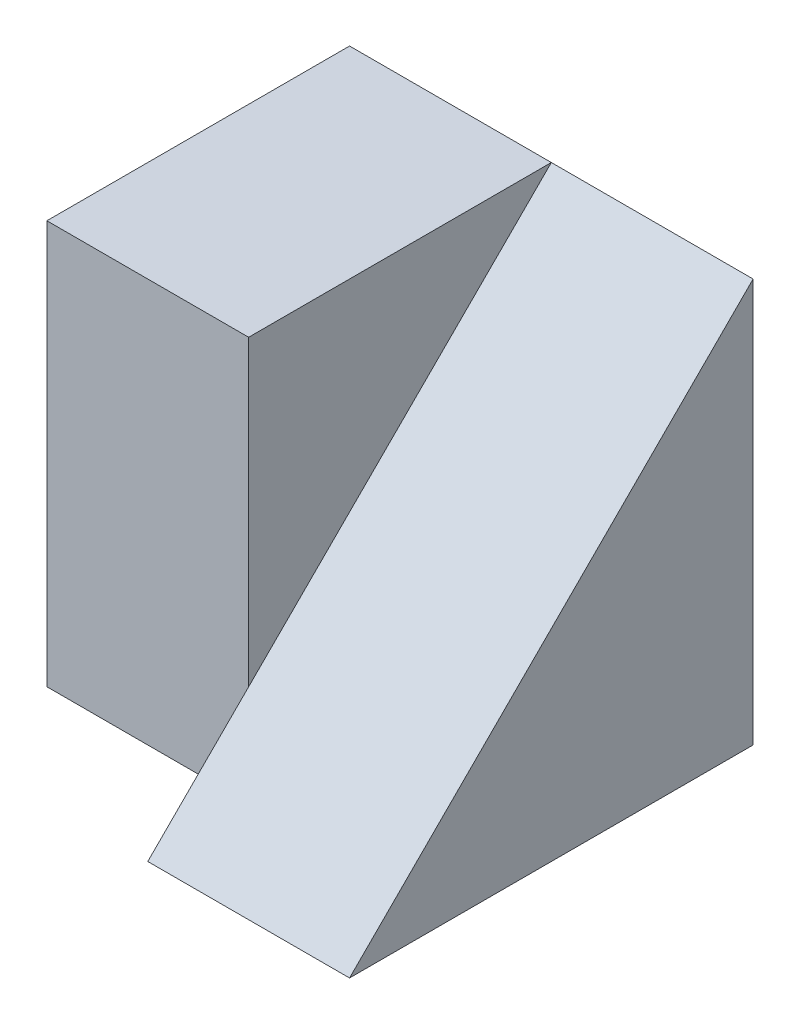
from build123d import *

# Parameters (mm, degrees)
SKETCH1_W           = 4
SKETCH1_H           = 4
BOSS_EXTRUDE1_DEPTH = 2
SKETCH2_W           = 3
SKETCH2_H           = 4
BOSS_EXTRUDE2_DEPTH = 2
CUT_EXTRUDE1_DEPTH  = 2
CUT_EXTRUDE2_DEPTH  = 2


with BuildPart() as part:
    # Sketch1 → Boss-Extrude1 (new body)
    with BuildSketch(Plane(origin=(0, 0, 0), x_dir=(0, 0, -1), z_dir=(1, 0, 0))):
        with Locations((2, 2)):
            Rectangle(SKETCH1_W, SKETCH1_H)
    extrude(amount=BOSS_EXTRUDE1_DEPTH)

    # Sketch2 → Boss-Extrude2 (add)
    with BuildSketch(Plane.ZY):
        with Locations((-2.5, 2)):
            Rectangle(SKETCH2_W, SKETCH2_H)
    extrude(amount=BOSS_EXTRUDE2_DEPTH)

    # Sketch3 → Cut-Extrude1 (cut)
    with BuildSketch(Plane(origin=(2, 0, 0), x_dir=(0, 0, -1), z_dir=(1, 0, 0))):
        Polygon((4, 4), (0, 0), (0, 4), align=None)
    extrude(amount=-CUT_EXTRUDE1_DEPTH, mode=Mode.SUBTRACT)

    # Sketch4 → Cut-Extrude2 (cut)
    with BuildSketch(Plane.ZY.offset(2)):
        Polygon((-1, 0), (-4, 4), (-4, 0), align=None)
    extrude(amount=-CUT_EXTRUDE2_DEPTH, mode=Mode.SUBTRACT)


solid = part.part
